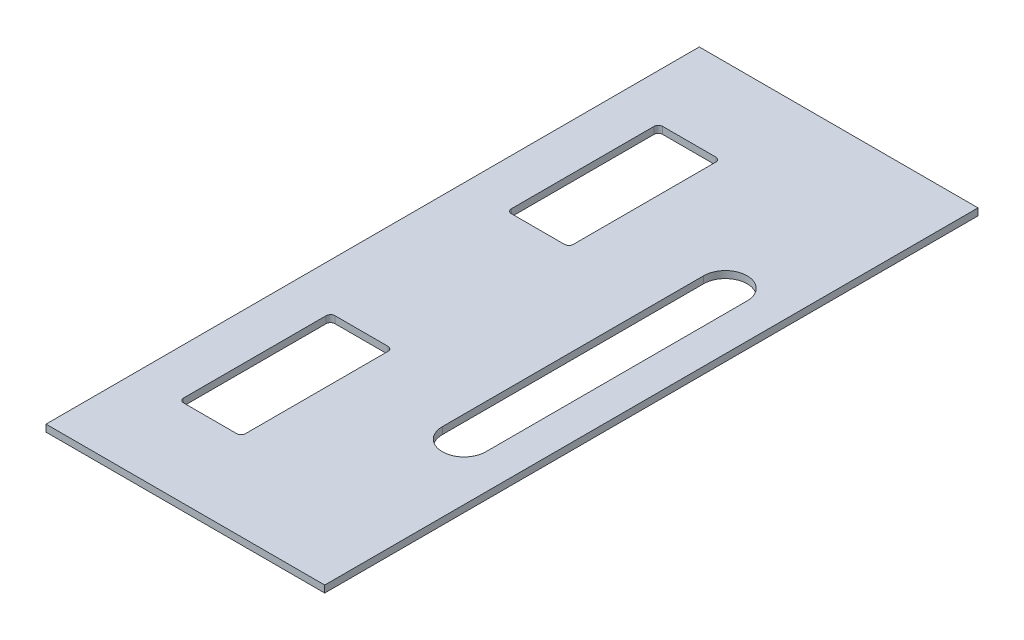
from build123d import *

# Parameters (mm, degrees)
SKETCH4_W           = 320
SKETCH4_H           = 750
BOSS_EXTRUDE3_DEPTH = 8
CUT_EXTRUDE1_DEPTH  = 8


with BuildPart() as part:
    # Sketch4 → Boss-Extrude3 (new body)
    with BuildSketch(Plane(origin=(0, 0, 0), x_dir=(1, 0, 0), z_dir=(0, 1, 0))):
        with Locations((160, 375)):
            Rectangle(SKETCH4_W, SKETCH4_H)
    extrude(amount=BOSS_EXTRUDE3_DEPTH)

    # Sketch8 → Cut-Extrude1 (cut)
    with BuildSketch(Plane(origin=(0, 8, 0), x_dir=(1, 0, 0), z_dir=(0, 1, 0))):
        with BuildLine():
            Line((119, 100), (58, 100))
            ThreePointArc((58, 100), (54.464466094, 101.464466094), (53, 105))
            Line((53, 105), (53, 268.675816019))
            ThreePointArc((53, 268.675816019), (54.464466094, 272.211349925), (58, 273.675816019))
            Line((58, 273.675816019), (119, 273.675816019))
            ThreePointArc((119, 273.675816019), (122.535533906, 272.211349925), (124, 268.675816019))
            Line((124, 268.675816019), (124, 105))
            ThreePointArc((124, 105), (122.535533906, 101.464466094), (119, 100))
        make_face()
        with BuildLine():
            Line((230, 225), (230, 525))
            ThreePointArc((230, 525), (255, 550), (280, 525))
            Line((280, 525), (280, 225))
            ThreePointArc((280, 225), (255, 200), (230, 225))
        make_face()
        with BuildLine():
            Line((119, 476.324183981), (58, 476.324183981))
            ThreePointArc((58, 476.324183981), (54.464466094, 477.788650075), (53, 481.324183981))
            Line((53, 481.324183981), (53, 645))
            ThreePointArc((53, 645), (54.464466094, 648.535533906), (58, 650))
            Line((58, 650), (119, 650))
            ThreePointArc((119, 650), (122.535533906, 648.535533906), (124, 645))
            Line((124, 645), (124, 481.324183981))
            ThreePointArc((124, 481.324183981), (122.535533906, 477.788650075), (119, 476.324183981))
        make_face()
    extrude(amount=-CUT_EXTRUDE1_DEPTH, mode=Mode.SUBTRACT)


solid = part.part
